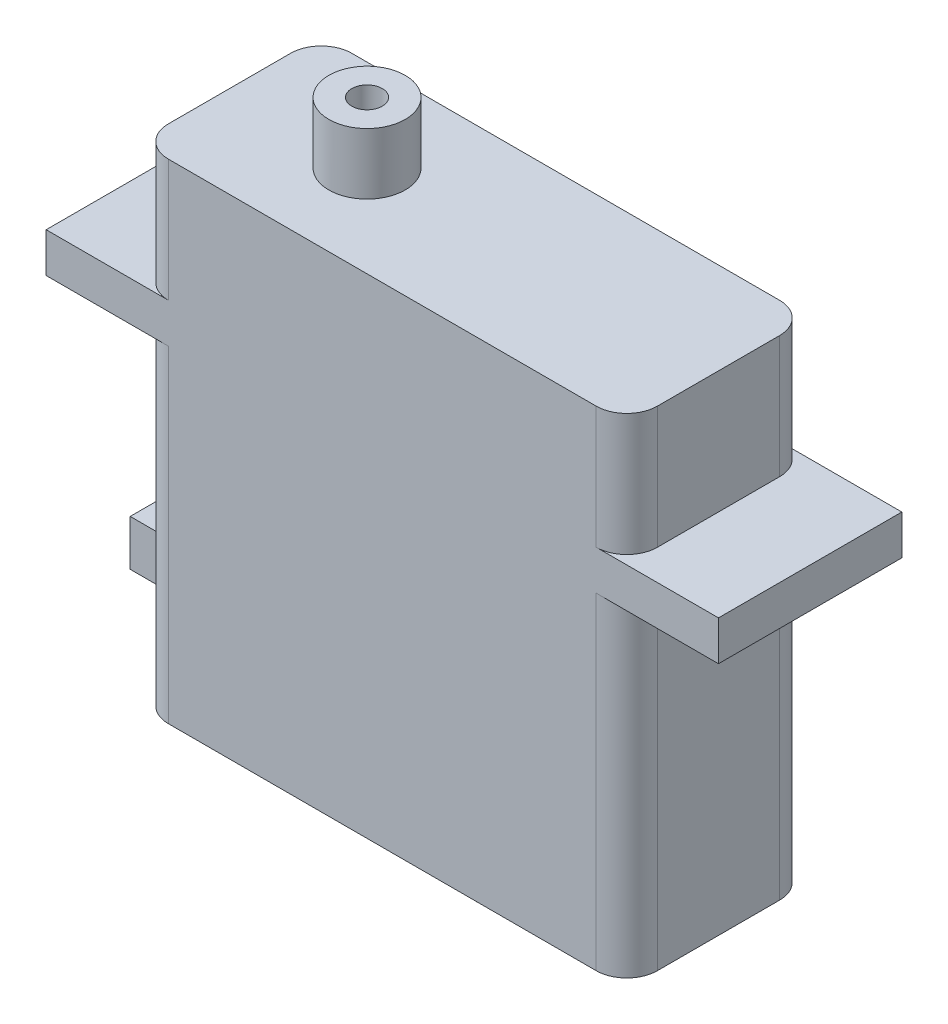
from build123d import *

# Parameters (mm, degrees)
SKETCH1_W                = 40.64
SKETCH1_H                = 40.64
BOSS_EXTRUDE1_DEPTH      = 15.24
SKETCH2_R                = 3.175
BOSS_EXTRUDE2_DEPTH      = 5.08
SKETCH3_R                = 1.27
CUT_EXTRUDE1_DEPTH       = 5.08
FILLET2_R                = 2.54
SKETCH4_W                = 6.35
SKETCH4_H                = 3.81
BOSS_EXTRUDE3_DEPTH      = 5.08
SKETCH5_W                = 15.24
SKETCH5_H                = 3.302
BOSS_EXTRUDE4_DEPTH      = 7.62
BOSS_EXTRUDE4_DEPTH_BACK = 2.54
SKETCH6_W                = 15.24
SKETCH6_H                = 3.302
BOSS_EXTRUDE5_DEPTH      = 7.62
BOSS_EXTRUDE5_DEPTH_BACK = 2.54


with BuildPart() as part:
    # Sketch1 → Boss-Extrude1 (new body)
    with BuildSketch(Plane.XY):
        with Locations((21.271438127, 20.32)):
            Rectangle(SKETCH1_W, SKETCH1_H)
    extrude(amount=BOSS_EXTRUDE1_DEPTH)

    # Sketch2 → Boss-Extrude2 (add)
    with BuildSketch(Plane(origin=(0, 40.64, 0), x_dir=(1, 0, 0), z_dir=(0, 1, 0))):
        with Locations((12.381438127, -7.62)):
            Circle(SKETCH2_R)
    extrude(amount=BOSS_EXTRUDE2_DEPTH)

    # Sketch3 → Cut-Extrude1 (cut)
    with BuildSketch(Plane(origin=(0, 45.72, 0), x_dir=(1, 0, 0), z_dir=(0, 1, 0))):
        with Locations((12.381438127, -7.62)):
            Circle(SKETCH3_R)
    extrude(amount=-CUT_EXTRUDE1_DEPTH, mode=Mode.SUBTRACT)

    # Fillet2
    fillet2_edges = [part.edges().sort_by_distance(p)[0] for p in [
        (41.591438127, 20.32, 15.24),
        (0.951438127, 20.32, 15.24),
        (41.591438127, 20.32, 0),
        (0.951438127, 20.32, 0),
    ]]
    fillet(fillet2_edges, radius=FILLET2_R)

    # Sketch4 → Boss-Extrude3 (add)
    with BuildSketch(Plane.ZY.offset(-0.951438127)):
        with Locations((7.62, 6.985)):
            Rectangle(SKETCH4_W, SKETCH4_H)
    extrude(amount=BOSS_EXTRUDE3_DEPTH)

    # Sketch5 → Boss-Extrude4 (add, two sides)
    with BuildSketch(Plane.ZY.offset(-0.951438127)) as boss_extrude4_sk:
        with Locations((7.62, 28.829)):
            Rectangle(SKETCH5_W, SKETCH5_H)
    extrude(amount=BOSS_EXTRUDE4_DEPTH)
    extrude(boss_extrude4_sk.sketch, amount=-BOSS_EXTRUDE4_DEPTH_BACK)

    # Sketch6 → Boss-Extrude5 (add, two sides)
    with BuildSketch(Plane(origin=(41.591438127, 0, 0), x_dir=(0, 0, -1), z_dir=(1, 0, 0))) as boss_extrude5_sk:
        with Locations((-7.62, 28.829)):
            Rectangle(SKETCH6_W, SKETCH6_H)
    extrude(amount=BOSS_EXTRUDE5_DEPTH)
    extrude(boss_extrude5_sk.sketch, amount=-BOSS_EXTRUDE5_DEPTH_BACK)


solid = part.part
